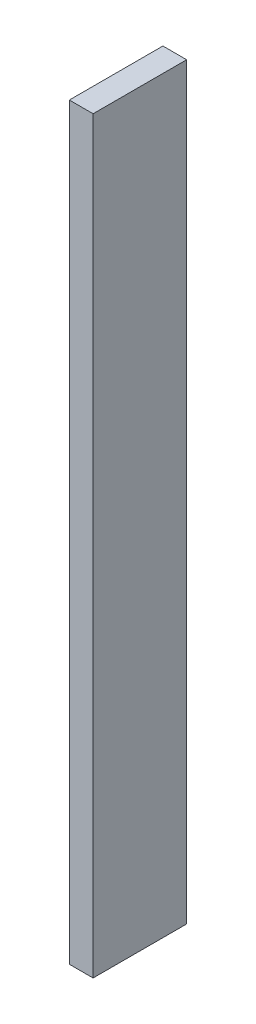
from build123d import *

# Parameters (mm, degrees)
SKETCH1_W           = 50
SKETCH1_H           = 400
BOSS_EXTRUDE1_DEPTH = 12.7


with BuildPart() as part:
    # Sketch1 → Boss-Extrude1 (new body)
    with BuildSketch(Plane(origin=(0, 0, 0), x_dir=(0, 0, -1), z_dir=(1, 0, 0))):
        Rectangle(SKETCH1_W, SKETCH1_H)
    extrude(amount=BOSS_EXTRUDE1_DEPTH)


solid = part.part
